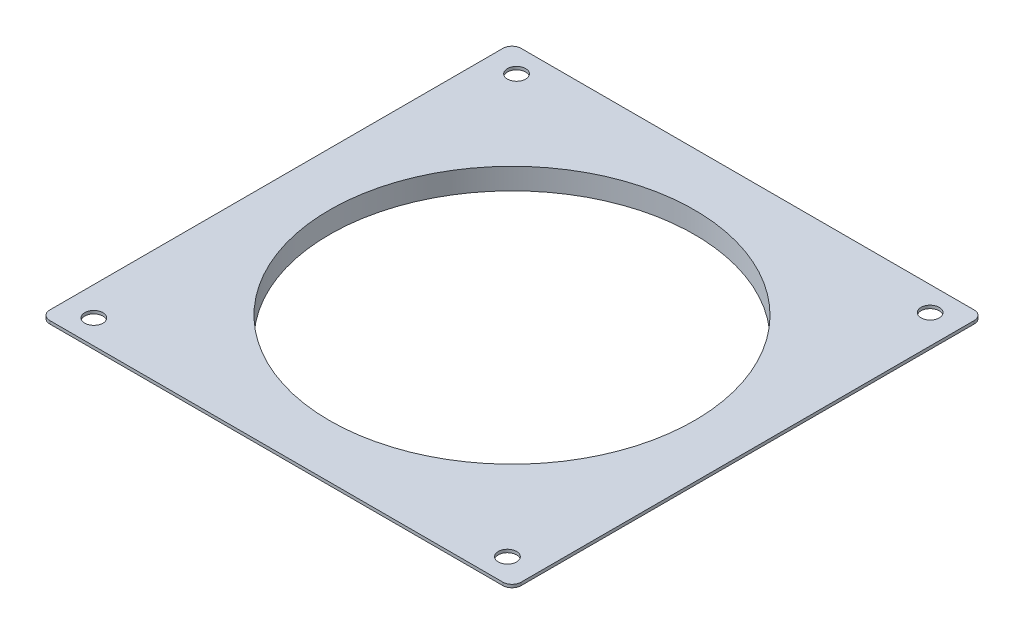
from build123d import *

# Parameters (mm, degrees)
SKETCH1_W           = 155
SKETCH1_H           = 155
SKETCH1_R           = 3
SKETCH1_R_2         = 60
BOSS_EXTRUDE1_DEPTH = 1
FILLET1_R           = 3
SKETCH2_R           = 65
SKETCH2_R_2         = 60
BOSS_EXTRUDE2_DEPTH = 7


with BuildPart() as part:
    # Sketch1 → Boss-Extrude1 (new body)
    with BuildSketch(Plane(origin=(0, 0, 0), x_dir=(1, 0, 0), z_dir=(0, 1, 0))):
        Rectangle(SKETCH1_W, SKETCH1_H)
        with Locations((-68, 69.5)):
            Circle(SKETCH1_R, mode=Mode.SUBTRACT)
        with Locations((68, 69.5)):
            Circle(SKETCH1_R, mode=Mode.SUBTRACT)
        with Locations((-68, -69.5)):
            Circle(SKETCH1_R, mode=Mode.SUBTRACT)
        with Locations((68, -69.5)):
            Circle(SKETCH1_R, mode=Mode.SUBTRACT)
        Circle(SKETCH1_R_2, mode=Mode.SUBTRACT)
    extrude(amount=BOSS_EXTRUDE1_DEPTH)

    # Fillet1
    fillet1_edges = [part.edges().sort_by_distance(p)[0] for p in [
        (77.5, 0.5, 77.5),
        (-77.5, 0.5, 77.5),
        (-77.5, 0.5, -77.5),
        (77.5, 0.5, -77.5),
    ]]
    fillet(fillet1_edges, radius=FILLET1_R)

    # Sketch2 → Boss-Extrude2 (add)
    with BuildSketch(Plane(origin=(0, 1, 0), x_dir=(1, 0, 0), z_dir=(0, 1, 0))):
        Circle(SKETCH2_R)
        Circle(SKETCH2_R_2, mode=Mode.SUBTRACT)
    extrude(amount=-BOSS_EXTRUDE2_DEPTH)


solid = part.part
